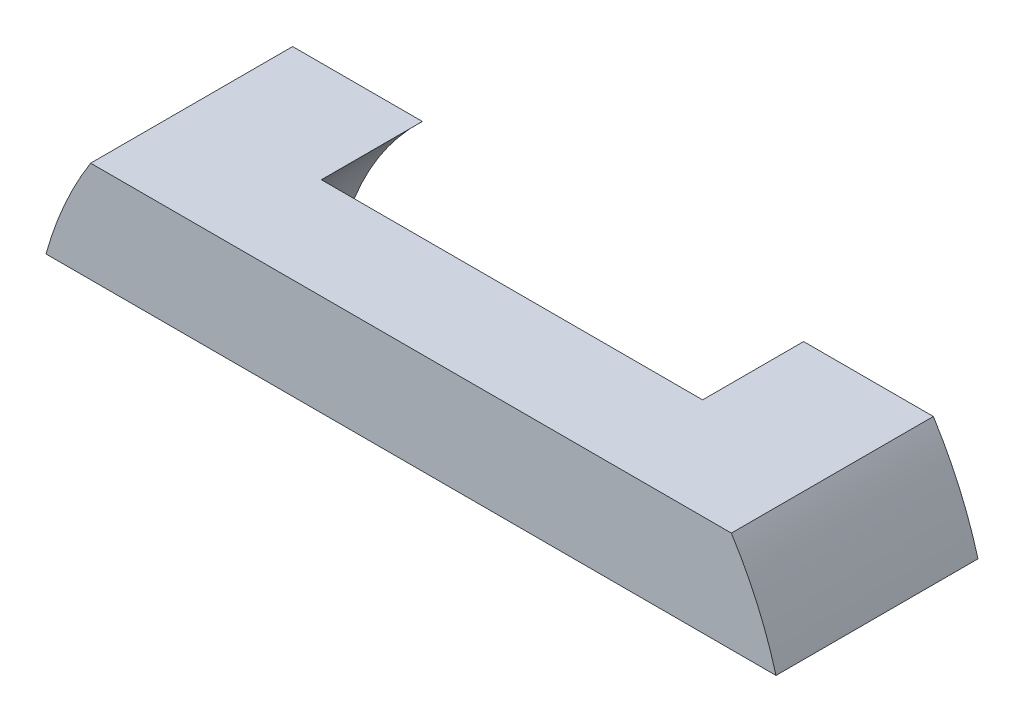
from build123d import *

# Parameters (mm, degrees)
BOSS_EXTRUDE2_DEPTH = 6.35
SKETCH5_R           = 8.73125
CUT_EXTRUDE1_DEPTH  = 3.175


with BuildPart() as part:
    # Sketch3 → Boss-Extrude2 (new body)
    with BuildSketch(Plane.XY):
        with BuildLine():
            Line((-10.071558423, 6.35), (10.071558423, 6.35))
            ThreePointArc((10.071558423, 6.35), (10.8896691, 4.81392729), (11.475110634, 3.175))
            Line((11.475110634, 3.175), (-11.475110634, 3.175))
            ThreePointArc((-11.475110634, 3.175), (-10.8896691, 4.81392729), (-10.071558423, 6.35))
        make_face()
    extrude(amount=BOSS_EXTRUDE2_DEPTH)

    # Sketch5 → Cut-Extrude1 (cut)
    with BuildSketch(Plane(origin=(0, 0, 0), x_dir=(-1, 0, 0), z_dir=(0, 0, -1))):
        Circle(SKETCH5_R)
    extrude(amount=-CUT_EXTRUDE1_DEPTH, mode=Mode.SUBTRACT)


solid = part.part
